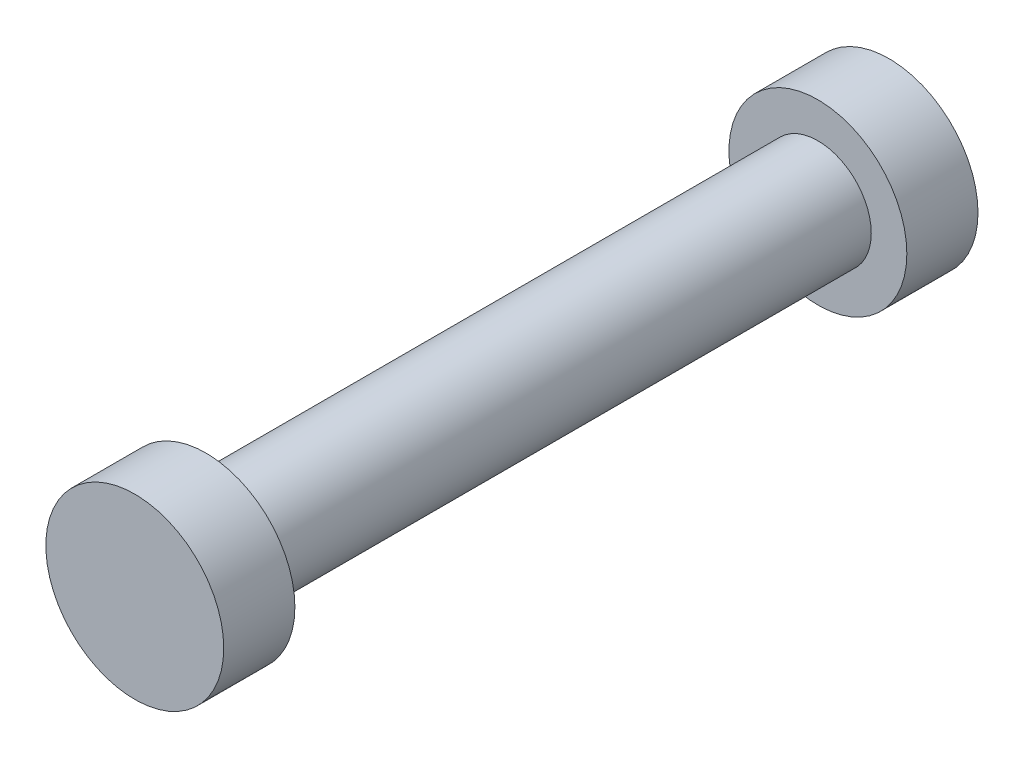
from build123d import *

# Parameters (mm, degrees)
SKETCH1_R           = 12.5
BOSS_EXTRUDE1_DEPTH = 10
SKETCH2_R           = 7.5
BOSS_EXTRUDE2_DEPTH = 86
SKETCH4_R           = 12.5
BOSS_EXTRUDE3_DEPTH = 10


with BuildPart() as part:
    # Sketch1 → Boss-Extrude1 (new body)
    with BuildSketch(Plane.XY):
        Circle(SKETCH1_R)
    extrude(amount=BOSS_EXTRUDE1_DEPTH)

    # Sketch2 → Boss-Extrude2 (add)
    with BuildSketch(Plane.XY.offset(10)):
        Circle(SKETCH2_R)
    extrude(amount=BOSS_EXTRUDE2_DEPTH)

    # Sketch4 → Boss-Extrude3 (add)
    with BuildSketch(Plane.XY.offset(96)):
        Circle(SKETCH4_R)
    extrude(amount=BOSS_EXTRUDE3_DEPTH)


solid = part.part
